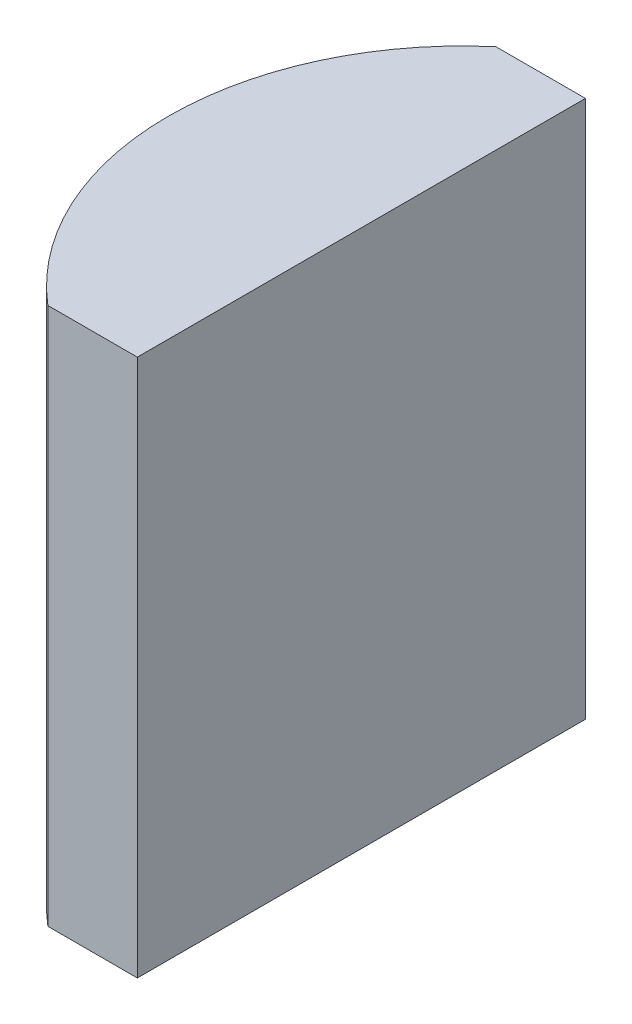
from build123d import *

# Parameters (mm, degrees)
EXTRUDE_1_DEPTH = 12


with BuildPart() as part:
    # 草图1 → 凸台-拉伸1 (new body)
    with BuildSketch(Plane(origin=(0, 0, 0), x_dir=(1, 0, 0), z_dir=(0, 1, 0))):
        with BuildLine():
            Line((0.108605696, 5), (2.105204335, 5))
            Line((2.105204335, 5), (2.105204335, -5))
            Line((2.105204335, -5), (0.108605696, -5))
            ThreePointArc((0.108605696, -5), (-2.204795665, 0), (0.108605696, 5))
        make_face()
    extrude(amount=EXTRUDE_1_DEPTH)


solid = part.part
